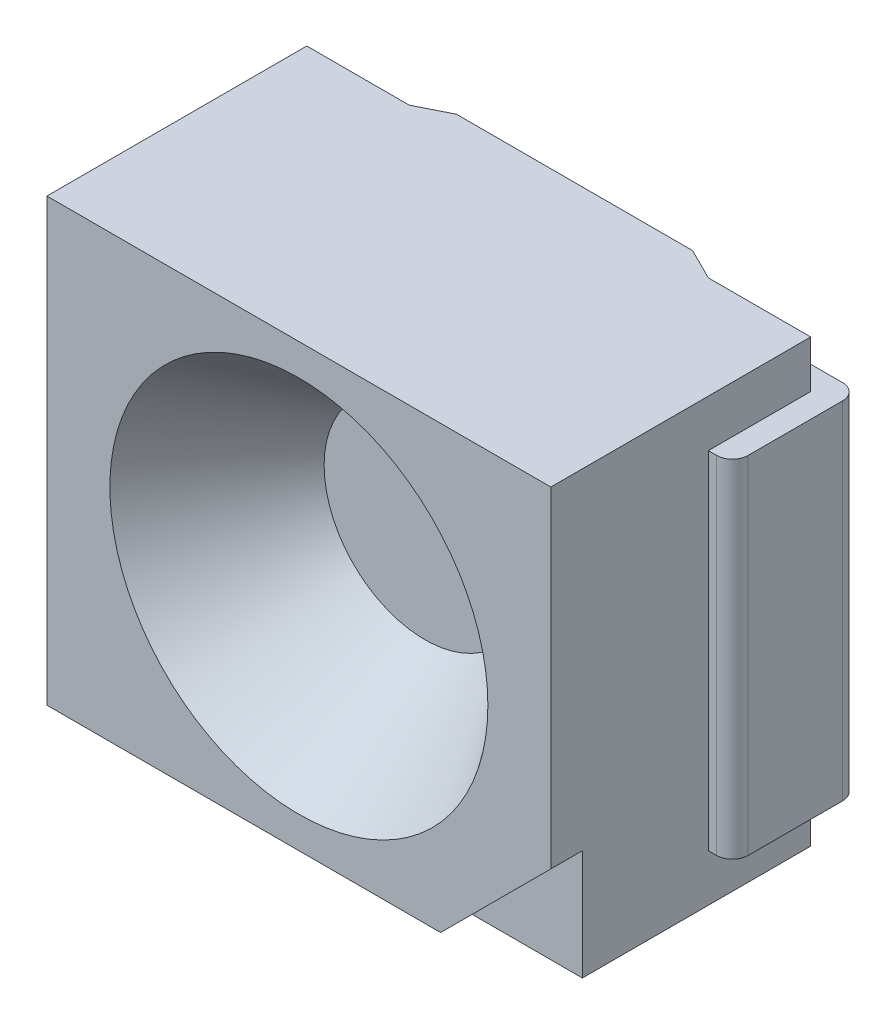
from build123d import *

# Parameters (mm, degrees)
SKETCH1_W           = 3.2
SKETCH1_H           = 2.8
BOSS_EXTRUDE1_DEPTH = 1.75
CUT_EXTRUDE1_DEPTH  = 0.2
SKETCH3_R           = 1.2
CUT_EXTRUDE2_DEPTH  = 0.8
CUT_EXTRUDE2_TAPER  = 35
CUT_EXTRUDE3_DEPTH  = 3.8
SKETCH6_W           = 0.8
SKETCH6_H           = 2.2
BOSS_EXTRUDE3_DEPTH = 0.15
SKETCH7_W           = 0.15
SKETCH7_H           = 2.2
SKETCH7_W_2         = 0.152457207
BOSS_EXTRUDE4_DEPTH = 0.65
FILLET1_R           = 0.1
SKETCH8_R           = 0.3
CUT_EXTRUDE4_DEPTH  = 0.2


with BuildPart() as part:
    # Sketch1 → Boss-Extrude1 (new body)
    with BuildSketch(Plane.XY):
        with Locations((1.6, 1.4)):
            Rectangle(SKETCH1_W, SKETCH1_H)
    extrude(amount=BOSS_EXTRUDE1_DEPTH)

    # Sketch2 → Cut-Extrude1 (cut)
    with BuildSketch(Plane.XY.offset(1.75)):
        Polygon((3.2, 0), (3.2, 0.7), (2.5, 0), align=None)
    extrude(amount=-CUT_EXTRUDE1_DEPTH, mode=Mode.SUBTRACT)

    # Sketch3 → Cut-Extrude2 (cut)
    with BuildSketch(Plane.XY.offset(1.75)):
        with Locations((1.6, 1.4)):
            Circle(SKETCH3_R)
    extrude(amount=-CUT_EXTRUDE2_DEPTH, taper=CUT_EXTRUDE2_TAPER, mode=Mode.SUBTRACT)

    # Sketch5 → Cut-Extrude3 (cut, through all)
    with BuildSketch(Plane.XZ):
        Polygon((0, 0.1), (0.65, 0.1), (0.85, 0), (0.65, 0), (0, 0), align=None)
        Polygon((2.55, 0.1), (3.2, 0.1), (3.2, 0), (2.55, 0), (2.35, 0), align=None)
    extrude(amount=-CUT_EXTRUDE3_DEPTH, mode=Mode.SUBTRACT)

    # Sketch6 → Boss-Extrude3 (add)
    with BuildSketch(Plane(origin=(0, 0, 0.1), x_dir=(-1, 0, 0), z_dir=(0, 0, -1))):
        with Locations((-2.952457207, 1.4)):
            Rectangle(SKETCH6_W, SKETCH6_H)
        with Locations((-0.25, 1.4)):
            Rectangle(SKETCH6_W, SKETCH6_H)
    extrude(amount=BOSS_EXTRUDE3_DEPTH)

    # Sketch7 → Boss-Extrude4 (add)
    with BuildSketch(Plane.XY.offset(0.1)):
        with Locations((-0.075, 1.4)):
            Rectangle(SKETCH7_W, SKETCH7_H)
        with Locations((3.276228603, 1.4)):
            Rectangle(SKETCH7_W_2, SKETCH7_H)
    extrude(amount=BOSS_EXTRUDE4_DEPTH)

    # Fillet1
    fillet1_edges = [part.edges().sort_by_distance(p)[0] for p in [
        (3.352457207, 1.4, 0.75),
        (3.352457207, 1.4, -0.05),
        (-0.15, 1.4, -0.05),
        (-0.15, 1.4, 0.75),
    ]]
    fillet(fillet1_edges, radius=FILLET1_R)

    # Sketch8 → Cut-Extrude4 (cut)
    with BuildSketch(Plane(origin=(0, 0, 0), x_dir=(-1, 0, 0), z_dir=(0, 0, -1))):
        with Locations((-1.6, 1.4)):
            Circle(SKETCH8_R)
    extrude(amount=-CUT_EXTRUDE4_DEPTH, mode=Mode.SUBTRACT)


solid = part.part
